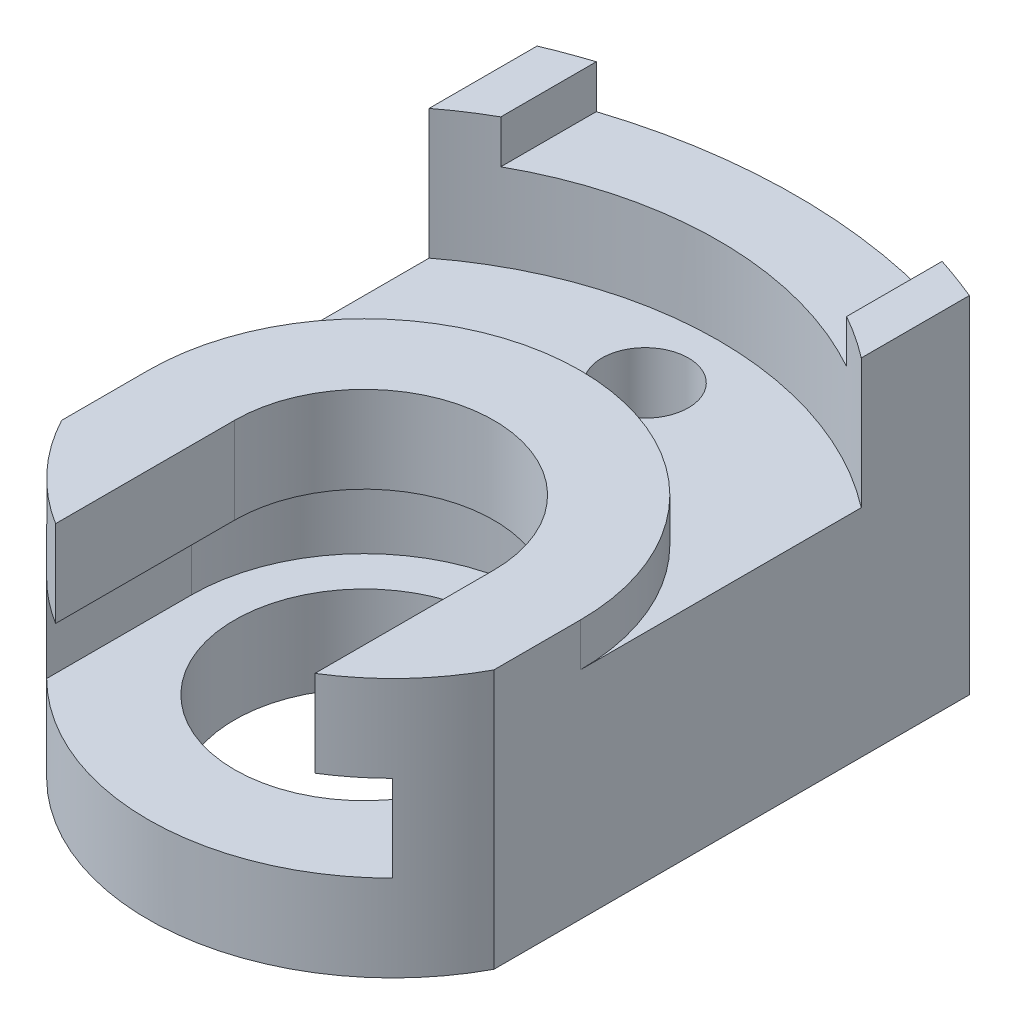
from build123d import *

# Parameters (mm, degrees)
BOSS_EXTRUDE1_DEPTH = 7.5
SKETCH2_R           = 0.5
SKETCH2_R_2         = 3
CUT_EXTRUDE1_DEPTH  = 15
CUT_EXTRUDE2_DEPTH  = 3
CUT_EXTRUDE3_DEPTH  = 2
CUT_EXTRUDE4_DEPTH  = 2
CUT_EXTRUDE5_DEPTH  = 3
SKETCH8_R           = 1
CUT_EXTRUDE6_DEPTH  = 2


with BuildPart() as part:
    # Sketch1 → Boss-Extrude1 (new body, symmetric)
    with BuildSketch(Plane.XY):
        Polygon((-5, 4), (-5, -4), (5, -4), (5, 4), (4, 4), (4, 3), (-4, 3), (-4, 4), align=None)
    extrude(amount=BOSS_EXTRUDE1_DEPTH, both=True)

    # Sketch2 → Cut-Extrude1 (cut)
    with BuildSketch(Plane(origin=(0, 4, 0), x_dir=(1, 0, 0), z_dir=(0, 1, 0))):
        with BuildLine():
            Line((-5, 7.5), (-5, 6.5))
            ThreePointArc((-5, 6.5), (-2.549509757, 7.247548784), (0, 7.5))
            Line((0, 7.5), (-5, 7.5))
        make_face()
        with BuildLine():
            Line((4, 7.5), (0, 7.5))
            ThreePointArc((0, 7.5), (2.02470746, 7.341361287), (4, 6.869316877))
            Line((4, 6.869316877), (4, 7.5))
        make_face()
        with BuildLine():
            Line((5, 7.5), (4, 7.5))
            Line((4, 7.5), (4, 6.869316877))
            ThreePointArc((4, 6.869316877), (4.503787155, 6.694912926), (5, 6.5))
            Line((5, 6.5), (5, 7.5))
        make_face()
        with Locations((0, 4)):
            Circle(SKETCH2_R)
        with BuildLine():
            Line((-5, -7.5), (0, -7.5))
            ThreePointArc((0, -7.5), (-2.915475947, -6.692459912), (-5, -4.5))
            Line((-5, -4.5), (-5, -7.5))
        make_face()
        with BuildLine():
            ThreePointArc((5, -4.5), (4.550135794, -5.210813958), (4, -5.847198193))
            Line((4, -5.847198193), (4, -7.5))
            Line((4, -7.5), (5, -7.5))
            Line((5, -7.5), (5, -4.5))
        make_face()
        with BuildLine():
            Line((4, -7.5), (4, -5.847198193))
            ThreePointArc((4, -5.847198193), (2.164009809, -7.070524628), (0, -7.5))
            Line((0, -7.5), (4, -7.5))
        make_face()
        with Locations((0, -2.5)):
            Circle(SKETCH2_R_2)
    extrude(amount=-CUT_EXTRUDE1_DEPTH, mode=Mode.SUBTRACT)

    # Sketch4 → Cut-Extrude2 (cut)
    with BuildSketch(Plane(origin=(0, 3, 0), x_dir=(1, 0, 0), z_dir=(0, 1, 0))):
        with BuildLine():
            Line((3, -2.5), (3, -9.188092465))
            ThreePointArc((3, -9.188092465), (0, -12.188092465), (-3, -9.188092465))
            Line((-3, -9.188092465), (-3, -2.5))
            ThreePointArc((-3, -2.5), (0, 0.5), (3, -2.5))
        make_face()
    extrude(amount=-CUT_EXTRUDE2_DEPTH, mode=Mode.SUBTRACT)

    # Sketch5 → Cut-Extrude3 (cut)
    with BuildSketch(Plane(origin=(0, 0, 0), x_dir=(1, 0, 0), z_dir=(0, 1, 0))):
        with BuildLine():
            Line((4, -2.5), (4, -8.475889446))
            ThreePointArc((4, -8.475889446), (0, -12.475889446), (-4, -8.475889446))
            Line((-4, -8.475889446), (-4, -2.5))
            ThreePointArc((-4, -2.5), (0, 1.5), (4, -2.5))
        make_face()
    extrude(amount=-CUT_EXTRUDE3_DEPTH, mode=Mode.SUBTRACT)

    # Sketch6 → Cut-Extrude4 (cut)
    with BuildSketch(Plane(origin=(0, 4, 0), x_dir=(1, 0, 0), z_dir=(0, 1, 0))):
        with BuildLine():
            Line((5, -2.5), (5, -8.536359525))
            ThreePointArc((5, -8.536359525), (0, -13.536359525), (-5, -8.536359525))
            Line((-5, -8.536359525), (-5, -2.5))
            ThreePointArc((-5, -2.5), (0, 2.5), (5, -2.5))
        make_face()
    extrude(amount=-CUT_EXTRUDE4_DEPTH, mode=Mode.SUBTRACT)

    # Sketch7 → Cut-Extrude5 (cut)
    with BuildSketch(Plane(origin=(0, 4, 0), x_dir=(1, 0, 0), z_dir=(0, 1, 0))):
        with BuildLine():
            Line((-5, -2.5), (-5, 4))
            ThreePointArc((-5, 4), (0, 5.700609733), (5, 4))
            Line((5, 4), (5, -2.5))
            ThreePointArc((5, -2.5), (0, 2.5), (-5, -2.5))
        make_face()
    extrude(amount=-CUT_EXTRUDE5_DEPTH, mode=Mode.SUBTRACT)

    # Sketch8 → Cut-Extrude6 (cut)
    with BuildSketch(Plane(origin=(0, 1, 0), x_dir=(1, 0, 0), z_dir=(0, 1, 0))):
        with Locations((0, 4)):
            Circle(SKETCH8_R)
    extrude(amount=-CUT_EXTRUDE6_DEPTH, mode=Mode.SUBTRACT)


solid = part.part
